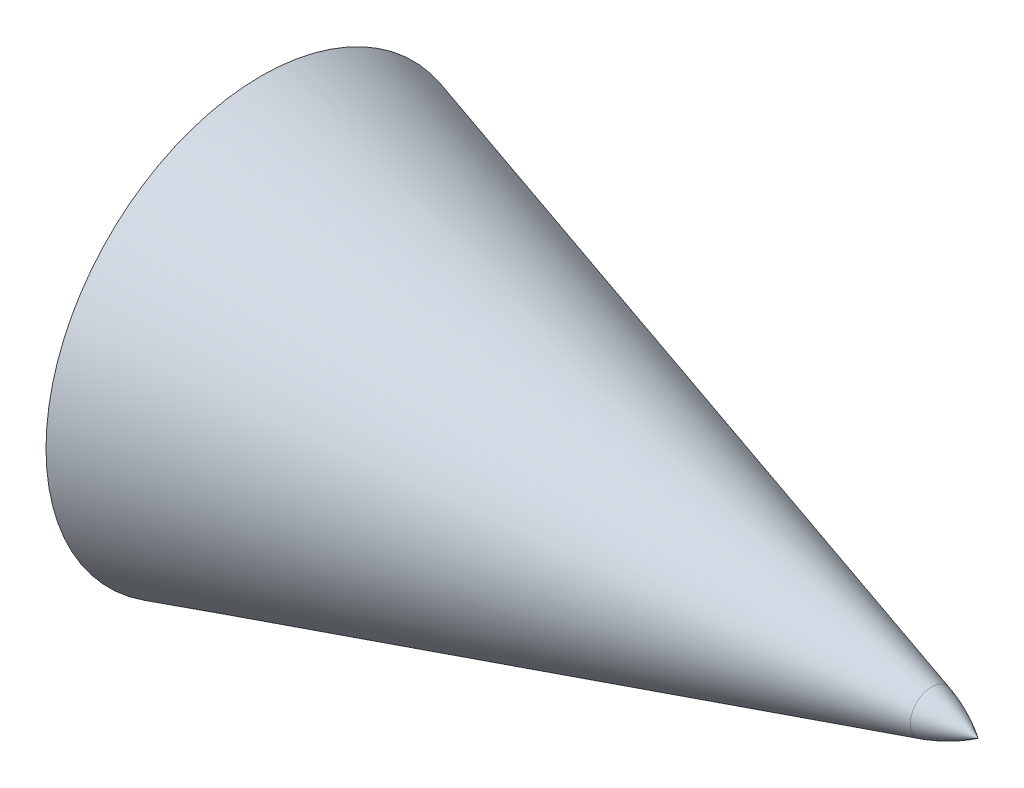
from build123d import *

# Parameters (mm, degrees)
CUT_EXTRUDE1_START = -50
SKETCH3_R          = 12.7
CUT_EXTRUDE1_DEPTH = 5


with BuildPart() as part:
    # Sketch1 → Revolve3 (revolve)
    with BuildSketch(Plane.XY):
        with BuildLine():
            Line((-50, 15), (-3.238025925, 1.484520566))
            ThreePointArc((-3.238025925, 1.484520566), (-1.563794514, 0.862702378), (0, 0))
            Line((0, 0), (-50, 0))
            Line((-50, 0), (-50, 15))
        make_face()
    revolve(axis=Axis((-90, 0, 0), (1, 0, 0)))

    # Sketch3 → Cut-Extrude1 (cut)
    with BuildSketch(Plane(origin=(0, 0, 0), x_dir=(0, 0, -1), z_dir=(1, 0, 0)).offset(CUT_EXTRUDE1_START)):
        Circle(SKETCH3_R)
    extrude(amount=CUT_EXTRUDE1_DEPTH, mode=Mode.SUBTRACT)


solid = part.part
